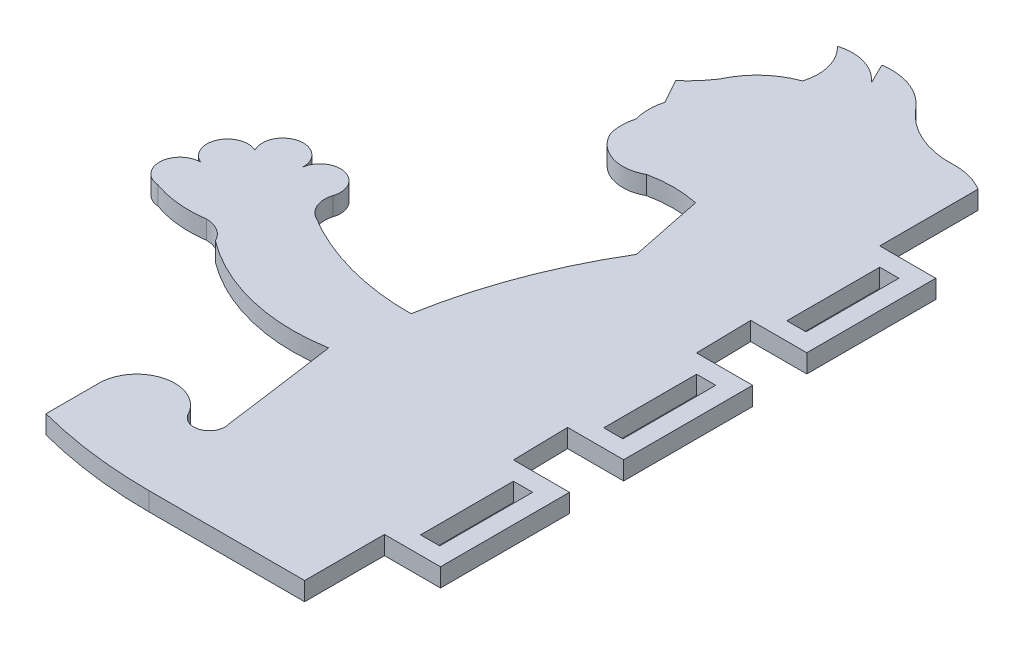
from build123d import *

# Parameters (mm, degrees)
CROQUIS1_W              = 3.123
CROQUIS1_H              = 15.123
SALIENTE_EXTRUIR1_DEPTH = 3


with BuildPart() as part:
    # Croquis1 → Saliente-Extruir1 (new body)
    with BuildSketch(Plane(origin=(0, 0, 0), x_dir=(1, 0, 0), z_dir=(0, 1, 0))):
        with BuildLine():
            Line((0, 0), (-25.35334021, 0))
            ThreePointArc((-25.35334021, 0), (-35.04114797, 0.617944908), (-44.571930081, 2.461763621))
            Line((-44.571930081, 2.461763621), (-44.571930081, 11.075732364))
            ThreePointArc((-44.571930081, 11.075732364), (-39.88555227, 17.072855397), (-32.933416744, 13.975205759))
            ThreePointArc((-32.933416744, 13.975205759), (-29.670426229, 12.826869208), (-28.256741004, 15.98396883))
            ThreePointArc((-28.256741004, 15.98396883), (-29.524185334, 25.374492899), (-30.842035613, 34.7580758))
            ThreePointArc((-30.842035613, 34.7580758), (-43.601286103, 35.166690974), (-55.146737973, 40.61352313))
            ThreePointArc((-55.146737973, 40.61352313), (-56.702332614, 42.340146226), (-58.936589522, 42.979832141))
            ThreePointArc((-58.936589522, 42.979832141), (-63.399357816, 42.873940264), (-67.75635917, 43.845564234))
            ThreePointArc((-67.75635917, 43.845564234), (-70.82154297, 47.338856104), (-67.432501244, 50.518924655))
            ThreePointArc((-67.432501244, 50.518924655), (-69.228649092, 54.977214613), (-64.711971431, 56.621027055))
            ThreePointArc((-64.711971431, 56.621027055), (-62.567152642, 61.508090829), (-58.457511411, 58.103022707))
            ThreePointArc((-58.457511411, 58.103022707), (-54.402954191, 60.902468919), (-51.964596359, 56.621027055))
            ThreePointArc((-51.964596359, 56.621027055), (-51.90610845, 54.077748681), (-50.284934749, 52.117268753))
            ThreePointArc((-50.284934749, 52.117268753), (-40.029435947, 47.704101098), (-28.955128653, 46.28599589))
            ThreePointArc((-28.955128653, 46.28599589), (-25.199651867, 60.10489344), (-18.969872724, 72.998899305))
            Line((-18.969872724, 72.998899305), (-21.43945093, 85.085877789))
            ThreePointArc((-21.43945093, 85.085877789), (-25.441052052, 85.50942601), (-29.442653175, 85.085877789))
            ThreePointArc((-29.442653175, 85.085877789), (-34.384513036, 84.587291983), (-38.103714758, 87.879419751))
            ThreePointArc((-38.103714758, 87.879419751), (-38.39022876, 89.973093944), (-38.103714758, 92.066768137))
            ThreePointArc((-38.103714758, 92.066768137), (-38.422657497, 94.422289333), (-38.103714758, 96.777810529))
            Line((-38.103714758, 96.777810529), (-40.264036145, 100.689922726))
            ThreePointArc((-40.264036145, 100.689922726), (-38.492328219, 102.483179814), (-36.944104715, 104.472582726))
            ThreePointArc((-36.944104715, 104.472582726), (-34.083877427, 108.433406386), (-29.91116369, 110.974564446))
            ThreePointArc((-29.91116369, 110.974564446), (-29.836790536, 115.134301556), (-31.962456815, 118.710680598))
            ThreePointArc((-31.962456815, 118.710680598), (-27.632984436, 118.696310735), (-24.032822758, 116.291446191))
            Line((-24.032822758, 116.291446191), (-25.681828786, 119.667114738))
            ThreePointArc((-25.681828786, 119.667114738), (-20.783837842, 119.164713826), (-16.785456287, 116.291446191))
            ThreePointArc((-16.785456287, 116.291446191), (-11.933782675, 112.593587472), (-5.939504059, 111.461545146))
            ThreePointArc((-5.939504059, 111.461545146), (-3.040196291, 111.1548194), (-0.363431198, 109.999399625))
            Line((-0.363431198, 109.999399625), (-0.363431198, 93.998899305))
            Line((-0.363431198, 93.998899305), (8.759568802, 93.998899305))
            Line((8.759568802, 93.998899305), (8.759568802, 72.998899305))
            Line((8.759568802, 72.998899305), (-0.363431198, 72.998899305))
            Line((-0.363431198, 72.998899305), (-0.181715599, 63.999449652))
            Line((-0.181715599, 63.999449652), (8.941284401, 63.999449652))
            Line((8.941284401, 63.999449652), (8.941284401, 42.999449652))
            Line((8.941284401, 42.999449652), (-0.181715599, 42.999449652))
            Line((-0.181715599, 42.999449652), (0, 34))
            Line((0, 34), (9.123, 34))
            Line((9.123, 34), (9.123, 13))
            Line((9.123, 13), (0, 13))
            Line((0, 13), (0, 0))
        make_face()
        with Locations((4.5615, 23.4385)):
            Rectangle(CROQUIS1_W, CROQUIS1_H, mode=Mode.SUBTRACT)
        with Locations((4.379784401, 53.437949652)):
            Rectangle(CROQUIS1_W, CROQUIS1_H, mode=Mode.SUBTRACT)
        with Locations((4.198068802, 83.437399305)):
            Rectangle(CROQUIS1_W, CROQUIS1_H, mode=Mode.SUBTRACT)
    extrude(amount=SALIENTE_EXTRUIR1_DEPTH)


solid = part.part
